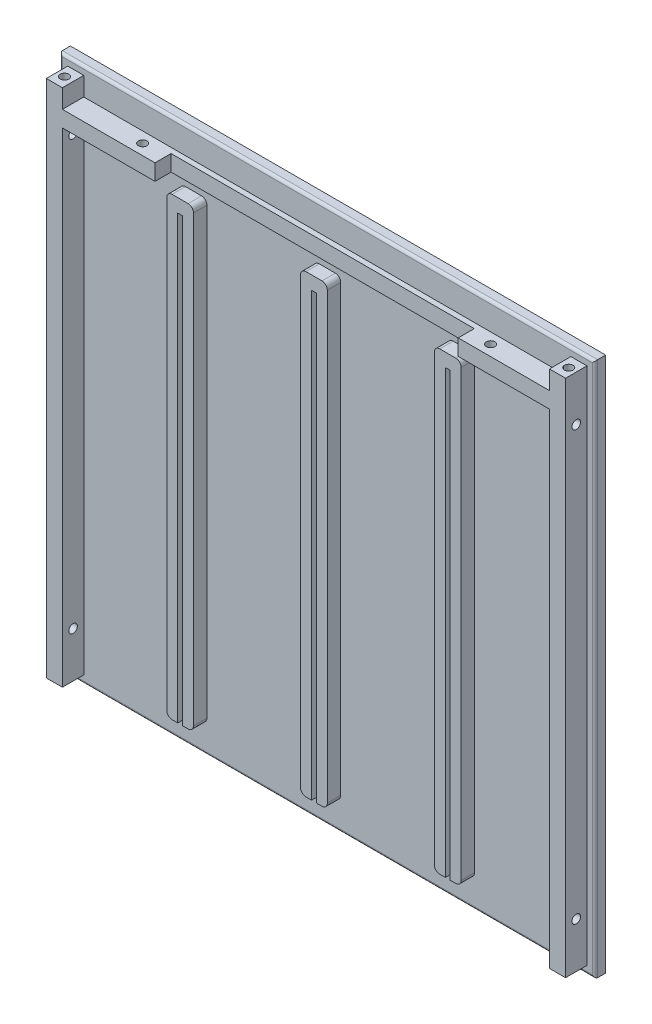
from build123d import *

# Parameters (mm, degrees)
ESQUISSE1_W                 = 200
ESQUISSE1_H                 = 200
BOSS_EXTRU_PAROIE_DEPTH     = 4
BOSS_EXTRU_BORDS_DEPTH      = 8
BOSS_EXTRU_GLISSIERES_DEPTH = 5
CONG_1_R                    = 1
ESQUISSE8_W                 = 1.8
ESQUISSE8_H                 = 180
ENL_V_MAT_EXTRU_6_DEPTH     = 9
ESQUISSE5_R                 = 1.6
ENL_V_MAT_EXTRU_2_DEPTH     = 10
ESQUISSE6_R                 = 1.6
ENL_V_MAT_EXTRU_3_DEPTH     = 10
ESQUISSE7_R                 = 1.6
ENL_V_MAT_EXTRU_4_DEPTH     = 10
ESQUISSE10_R                = 1.6
ENL_V_MAT_EXTRU_8_DEPTH     = 10
ESQUISSE11_W                = 113.303164178
ESQUISSE11_H                = 6
ENL_V_MAT_EXTRU_9_DEPTH     = 6
ESQUISSE9_R                 = 1.6
ENL_V_MAT_EXTRU_10_DEPTH    = 10


with BuildPart() as part:
    # Esquisse1 → Boss.-Extru. Paroie (new body)
    with BuildSketch(Plane.XY):
        with Locations((100, 100)):
            Rectangle(ESQUISSE1_W, ESQUISSE1_H)
    extrude(amount=BOSS_EXTRU_PAROIE_DEPTH)

    # Esquisse4 → Boss.-Extru. Bords (add)
    with BuildSketch(Plane.XY.offset(4)):
        Polygon((3, 3), (9, 3), (9, 184), (191, 184), (191, 3), (197, 3), (197, 197), (191, 197), (191, 190), (9, 190), (9, 197), (3, 197), align=None)
    extrude(amount=BOSS_EXTRU_BORDS_DEPTH)

    # Esquisse2 → Boss.-Extru. Glissieres (add)
    with BuildSketch(Plane.XY.offset(4)):
        with BuildLine():
            Line((47, 180), (53, 180))
            ThreePointArc((53, 180), (54.414213562, 179.414213562), (55, 178))
            Line((55, 178), (55, 12))
            ThreePointArc((55, 12), (54.414213562, 10.585786438), (53, 10))
            Line((53, 10), (47, 10))
            ThreePointArc((47, 10), (45.585786438, 10.585786438), (45, 12))
            Line((45, 12), (45, 178))
            ThreePointArc((45, 178), (45.585786438, 179.414213562), (47, 180))
        make_face()
        with BuildLine():
            Line((97, 180), (103, 180))
            ThreePointArc((103, 180), (104.414213562, 179.414213562), (105, 178))
            Line((105, 178), (105, 12))
            ThreePointArc((105, 12), (104.414213562, 10.585786438), (103, 10))
            Line((103, 10), (97, 10))
            ThreePointArc((97, 10), (95.585786438, 10.585786438), (95, 12))
            Line((95, 12), (95, 178))
            ThreePointArc((95, 178), (95.585786438, 179.414213562), (97, 180))
        make_face()
        with BuildLine():
            Line((147, 180), (153, 180))
            ThreePointArc((153, 180), (154.414213562, 179.414213562), (155, 178))
            Line((155, 178), (155, 12))
            ThreePointArc((155, 12), (154.414213562, 10.585786438), (153, 10))
            Line((153, 10), (147, 10))
            ThreePointArc((147, 10), (145.585786438, 10.585786438), (145, 12))
            Line((145, 12), (145, 178))
            ThreePointArc((145, 178), (145.585786438, 179.414213562), (147, 180))
        make_face()
    extrude(amount=BOSS_EXTRU_GLISSIERES_DEPTH)

    # Congé1
    cong_1_edges = [part.edges().sort_by_distance(p)[0] for p in [
        (200, 100, 4),
        (100, 200, 4),
        (0, 100, 4),
        (100, 0, 4),
    ]]
    fillet(cong_1_edges, radius=CONG_1_R)

    # Esquisse8 → Enlèv. mat.-Extru.6 (cut, through all)
    with BuildSketch(Plane.XY.offset(4)):
        with Locations((100, 85)):
            Rectangle(ESQUISSE8_W, ESQUISSE8_H)
        with Locations((150, 85)):
            Rectangle(ESQUISSE8_W, ESQUISSE8_H)
        with Locations((50, 85)):
            Rectangle(ESQUISSE8_W, ESQUISSE8_H)
    extrude(amount=ENL_V_MAT_EXTRU_6_DEPTH, mode=Mode.SUBTRACT)

    # Esquisse5 → Enlèv. mat.-Extru.2 (cut)
    with BuildSketch(Plane.ZY.offset(-3)):
        with Locations((8, 180)):
            Circle(ESQUISSE5_R)
        with Locations((8, 20)):
            Circle(ESQUISSE5_R)
    extrude(amount=-ENL_V_MAT_EXTRU_2_DEPTH, mode=Mode.SUBTRACT)

    # Esquisse6 → Enlèv. mat.-Extru.3 (cut)
    with BuildSketch(Plane(origin=(197, 0, 0), x_dir=(0, 0, -1), z_dir=(1, 0, 0))):
        with Locations((-8, 180)):
            Circle(ESQUISSE6_R)
        with Locations((-8, 20)):
            Circle(ESQUISSE6_R)
    extrude(amount=-ENL_V_MAT_EXTRU_3_DEPTH, mode=Mode.SUBTRACT)

    # Esquisse7 → Enlèv. mat.-Extru.4 (cut)
    with BuildSketch(Plane.XZ.offset(-184)):
        with Locations((35, 8)):
            Circle(ESQUISSE7_R)
        with Locations((165, 8)):
            Circle(ESQUISSE7_R)
    extrude(amount=-ENL_V_MAT_EXTRU_4_DEPTH, mode=Mode.SUBTRACT)

    # Esquisse10 → Enlèv. mat.-Extru.8 (cut)
    with BuildSketch(Plane(origin=(0, 3, 0), x_dir=(-1, 0, 0), z_dir=(0, -1, 0))):
        with Locations((-194.2, -8)):
            Circle(ESQUISSE10_R)
        with Locations((-5.8, -8)):
            Circle(ESQUISSE10_R)
    extrude(amount=-ENL_V_MAT_EXTRU_8_DEPTH, mode=Mode.SUBTRACT)

    # Esquisse11 → Enlèv. mat.-Extru.9 (cut)
    with BuildSketch(Plane.XY.offset(12)):
        with Locations((100.248809194, 187)):
            Rectangle(ESQUISSE11_W, ESQUISSE11_H)
    extrude(amount=-ENL_V_MAT_EXTRU_9_DEPTH, mode=Mode.SUBTRACT)

    # Esquisse9 → Enlèv. mat.-Extru.10 (cut)
    with BuildSketch(Plane(origin=(0, 197, 0), x_dir=(1, 0, 0), z_dir=(0, 1, 0))):
        with Locations((194.2, -8)):
            Circle(ESQUISSE9_R)
        with Locations((5.8, -8)):
            Circle(ESQUISSE9_R)
    extrude(amount=-ENL_V_MAT_EXTRU_10_DEPTH, mode=Mode.SUBTRACT)


solid = part.part
